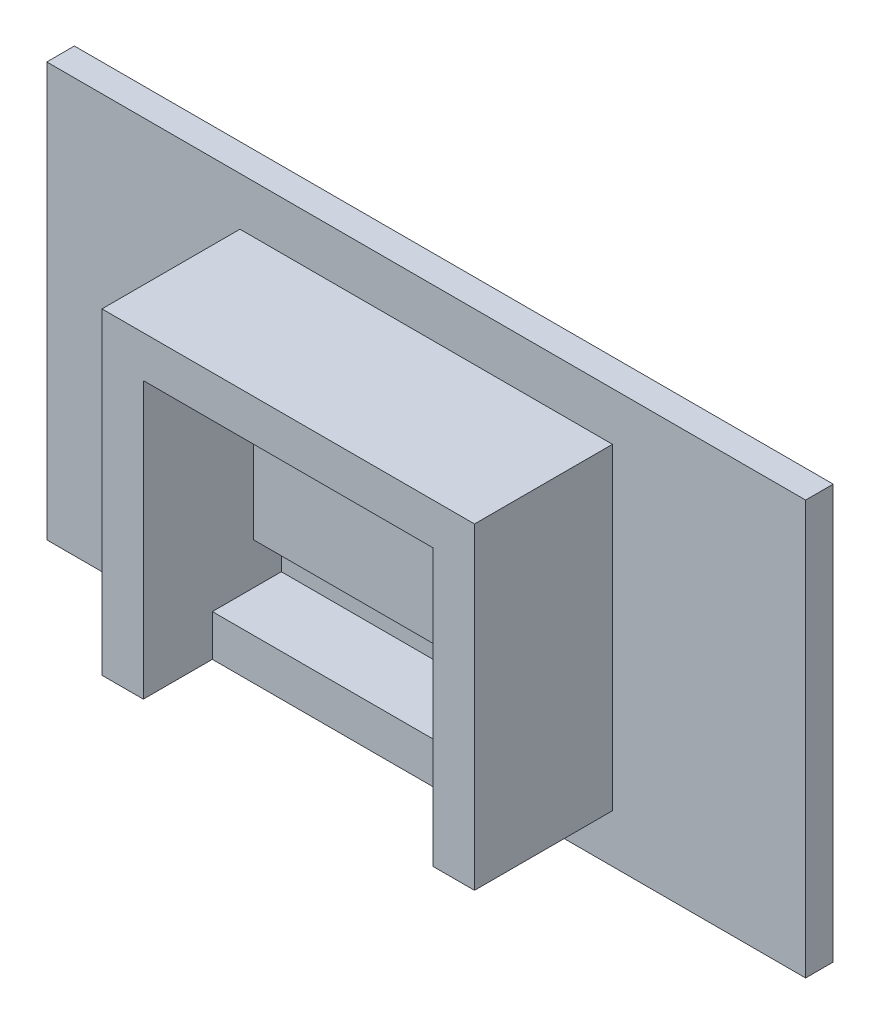
from build123d import *

# Parameters (mm, degrees)
SKETCH1_W           = 55
SKETCH1_H           = 30
BOSS_EXTRUDE2_DEPTH = 2
SKETCH8_W           = 27
SKETCH8_H           = 23
SKETCH8_W_2         = 21
SKETCH8_H_2         = 17
BOSS_EXTRUDE3_DEPTH = 10
SKETCH10_W          = 21
SKETCH10_H          = 14
BOSS_EXTRUDE4_DEPTH = 2
SKETCH13_W          = 21
SKETCH13_H          = 5
CUT_EXTRUDE3_DEPTH  = 3
SKETCH14_R          = 1.5
BOSS_EXTRUDE5_DEPTH = 3


with BuildPart() as part:
    # Sketch1 → Boss-Extrude2 (new body)
    with BuildSketch(Plane.XY):
        Rectangle(SKETCH1_W, SKETCH1_H)
    extrude(amount=BOSS_EXTRUDE2_DEPTH)

    # Sketch8 → Boss-Extrude3 (add)
    with BuildSketch(Plane.XY.offset(2)):
        Rectangle(SKETCH8_W, SKETCH8_H)
        Rectangle(SKETCH8_W_2, SKETCH8_H_2, mode=Mode.SUBTRACT)
    extrude(amount=BOSS_EXTRUDE3_DEPTH)

    # Sketch10 → Boss-Extrude4 (add)
    with BuildSketch(Plane.XY.offset(2)):
        with Locations((0, 1.5)):
            Rectangle(SKETCH10_W, SKETCH10_H)
    extrude(amount=BOSS_EXTRUDE4_DEPTH)

    # Sketch13 → Cut-Extrude3 (cut)
    with BuildSketch(Plane.XZ.offset(11.5)):
        with Locations((0, 9.5)):
            Rectangle(SKETCH13_W, SKETCH13_H)
    extrude(amount=-CUT_EXTRUDE3_DEPTH, mode=Mode.SUBTRACT)

    # Sketch14 → Boss-Extrude5 (add)
    with BuildSketch(Plane.XY.offset(4)):
        with Locations((-8, 6)):
            Circle(SKETCH14_R)
        with Locations((8, 6)):
            Circle(SKETCH14_R)
    extrude(amount=BOSS_EXTRUDE5_DEPTH)


solid = part.part
